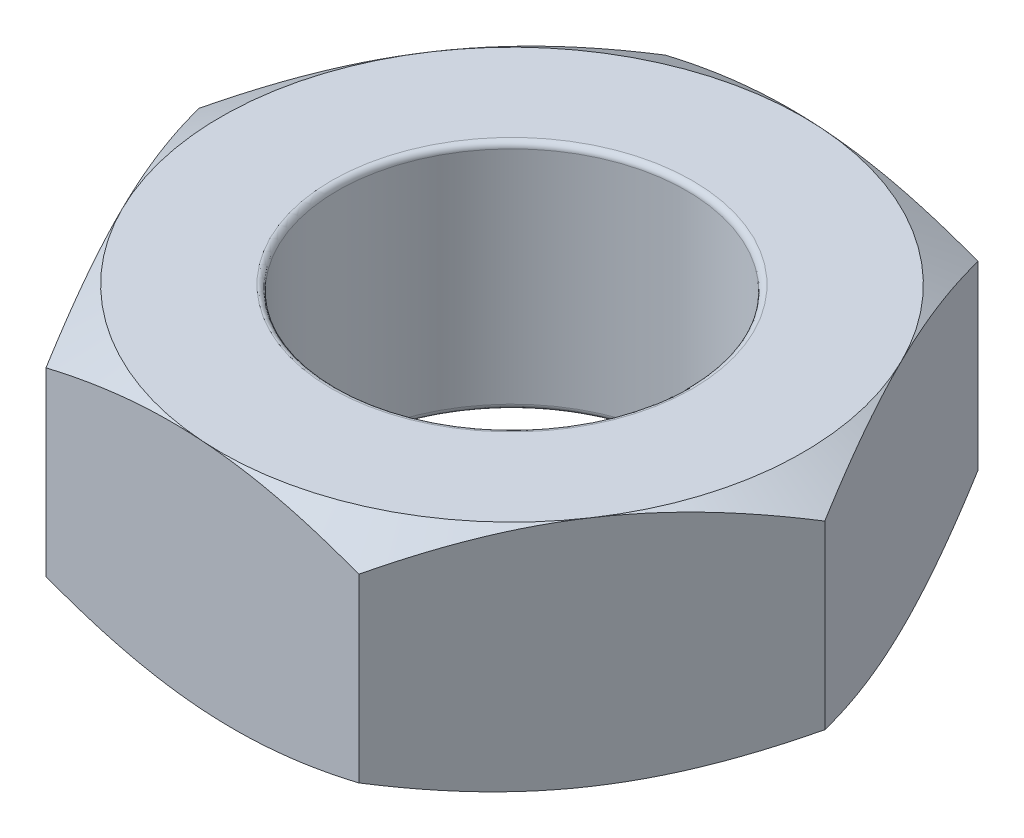
from build123d import *

# Parameters (mm, degrees)
SKETCH1_R           = 1.5
BOSS_EXTRUDE1_DEPTH = 2
SKETCH2_OUTSIDE_W   = 16.288
SKETCH2_OUTSIDE_H   = 15.71
SKETCH2_OUTSIDE_R   = 2.5
CUT_EXTRUDE1_DEPTH  = 2
CUT_EXTRUDE1_TAPER  = 60
SKETCH3_OUTSIDE_W   = 16.288
SKETCH3_OUTSIDE_H   = 15.71
SKETCH3_OUTSIDE_R   = 2.5
CUT_EXTRUDE2_DEPTH  = 2
CUT_EXTRUDE2_TAPER  = 60
FILLET1_R           = 0.05


with BuildPart() as part:
    # Sketch1 → Boss-Extrude1 (new body)
    with BuildSketch(Plane(origin=(0, 0, 0), x_dir=(1, 0, 0), z_dir=(0, 1, 0))):
        Polygon((-2.880337842, 0.192320694), (-1.606723528, -2.398285395), (1.273614314, -2.59060609), (2.880337842, -0.192320694), (1.606723528, 2.398285395), (-1.273614314, 2.59060609), align=None)
        Circle(SKETCH1_R, mode=Mode.SUBTRACT)
    extrude(amount=BOSS_EXTRUDE1_DEPTH)

    # Sketch2 outside → Cut-Extrude1 (cut)
    with BuildSketch(Plane(origin=(0, 2, 0), x_dir=(1, 0, 0), z_dir=(0, 1, 0))):
        Rectangle(SKETCH2_OUTSIDE_W, SKETCH2_OUTSIDE_H)
        Circle(SKETCH2_OUTSIDE_R, mode=Mode.SUBTRACT)
    extrude(amount=-CUT_EXTRUDE1_DEPTH, taper=CUT_EXTRUDE1_TAPER, mode=Mode.SUBTRACT)

    # Sketch3 outside → Cut-Extrude2 (cut)
    with BuildSketch(Plane.XZ):
        Rectangle(SKETCH3_OUTSIDE_W, SKETCH3_OUTSIDE_H)
        Circle(SKETCH3_OUTSIDE_R, mode=Mode.SUBTRACT)
    extrude(amount=-CUT_EXTRUDE2_DEPTH, taper=CUT_EXTRUDE2_TAPER, mode=Mode.SUBTRACT)

    # Fillet1
    fillet1_edges = [part.edges().sort_by_distance(p)[0] for p in [
        (-1.5, 0, 0),
        (-1.5, 2, 0),
    ]]
    fillet(fillet1_edges, radius=FILLET1_R)


solid = part.part
